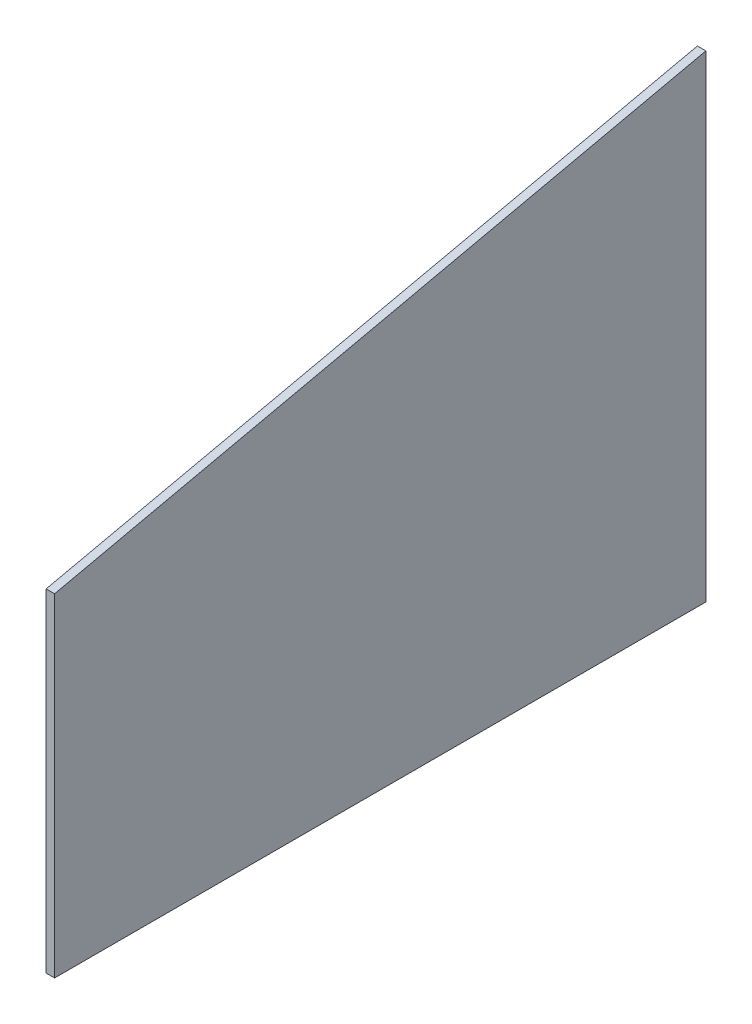
from build123d import *

# Parameters (mm, degrees)
BOSS_EXTRUDE1_DEPTH = 2.54


with BuildPart() as part:
    # Sketch1 → Boss-Extrude1 (new body)
    with BuildSketch(Plane(origin=(0, 0, 0), x_dir=(0, 0, -1), z_dir=(1, 0, 0))):
        Polygon((0, 0), (196.85, 0), (196.85, 144.272), (0, 100.584), align=None)
    extrude(amount=BOSS_EXTRUDE1_DEPTH)


solid = part.part
